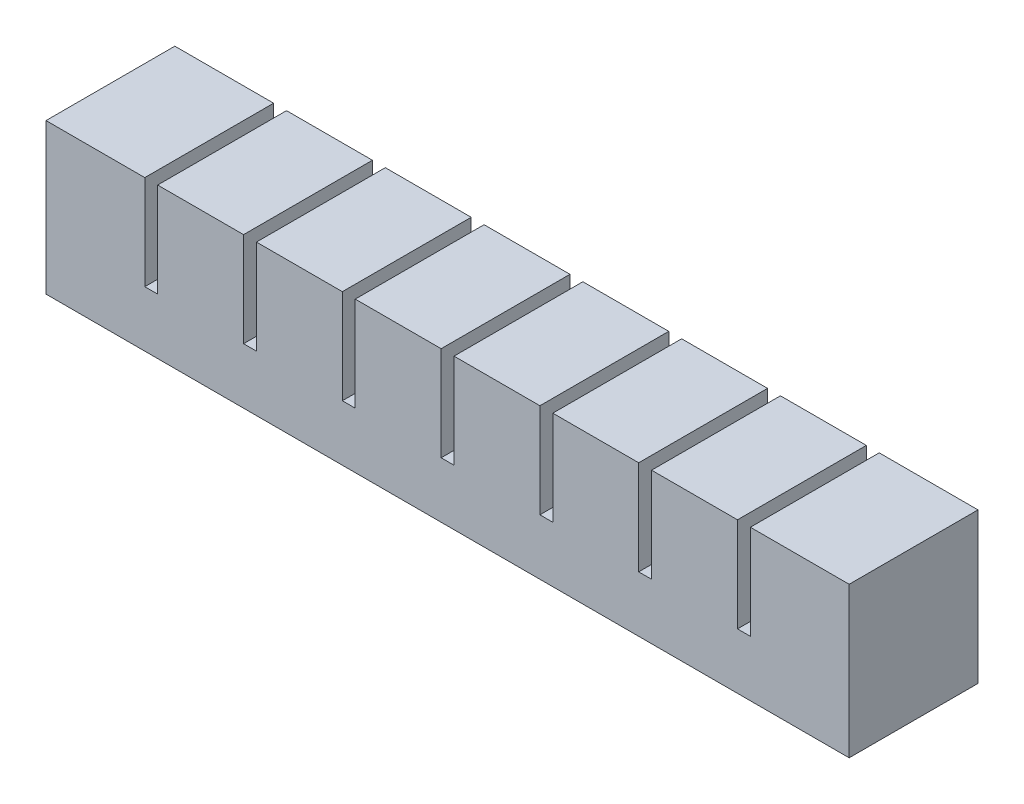
from build123d import *

# Parameters (mm, degrees)
SKETCH1_W           = 20
SKETCH1_H           = 30
BOSS_EXTRUDE1_DEPTH = 30
SKETCH2_W           = 10
SKETCH2_H           = 20
CUT_EXTRUDE1_DEPTH  = 25
SKETCH3_W           = 30
SKETCH3_H           = 8
BOSS_EXTRUDE2_DEPTH = 3
LPATTERN1_COUNT     = 8
LPATTERN1_PITCH     = 23
SKETCH4_W           = 30
SKETCH4_H           = 22
BOSS_EXTRUDE3_DEPTH = 3
SKETCH5_W           = 30
SKETCH5_H           = 30
BOSS_EXTRUDE4_DEPTH = 3
SKETCH6_W           = 151
SKETCH6_H           = 3
CUT_EXTRUDE2_DEPTH  = 3
SKETCH7_W           = 187
SKETCH7_H           = 30
BOSS_EXTRUDE5_DEPTH = 5


with BuildPart() as part:
    # Sketch1 → Boss-Extrude1 (new body)
    with BuildSketch(Plane.XY):
        with Locations((10, 15)):
            Rectangle(SKETCH1_W, SKETCH1_H)
    extrude(amount=BOSS_EXTRUDE1_DEPTH)

    # Sketch2 → Cut-Extrude1 (cut)
    with BuildSketch(Plane.XZ):
        with Locations((10, 15)):
            Rectangle(SKETCH2_W, SKETCH2_H)
    extrude(amount=-CUT_EXTRUDE1_DEPTH, mode=Mode.SUBTRACT)

    # Sketch3 → Boss-Extrude2 (add)
    with BuildSketch(Plane(origin=(20, 0, 0), x_dir=(0, 0, -1), z_dir=(1, 0, 0))):
        with Locations((-15, 4)):
            Rectangle(SKETCH3_W, SKETCH3_H)
    extrude(amount=BOSS_EXTRUDE2_DEPTH)


with BuildPart() as lpattern1_1:
    # LPattern1: pattern copy
    add(part.part.moved(Location(Vector(1, 0, 0) * (1 * LPATTERN1_PITCH))))


with BuildPart() as lpattern1_2:
    # LPattern1: pattern copy
    add(part.part.moved(Location(Vector(1, 0, 0) * (2 * LPATTERN1_PITCH))))


with BuildPart() as lpattern1_3:
    # LPattern1: pattern copy
    add(part.part.moved(Location(Vector(1, 0, 0) * (3 * LPATTERN1_PITCH))))


with BuildPart() as lpattern1_4:
    # LPattern1: pattern copy
    add(part.part.moved(Location(Vector(1, 0, 0) * (4 * LPATTERN1_PITCH))))


with BuildPart() as lpattern1_5:
    # LPattern1: pattern copy
    add(part.part.moved(Location(Vector(1, 0, 0) * (5 * LPATTERN1_PITCH))))


with BuildPart() as lpattern1_6:
    # LPattern1: pattern copy
    add(part.part.moved(Location(Vector(1, 0, 0) * (6 * LPATTERN1_PITCH))))


with BuildPart() as lpattern1_7:
    # LPattern1: pattern copy
    add(part.part.moved(Location(Vector(1, 0, 0) * (7 * LPATTERN1_PITCH))))

    # Combine1: union part, LPattern1_1, LPattern1_2, LPattern1_3, LPattern1_4, LPattern1_5, LPattern1_6
    add(part.part)
    add(lpattern1_1.part)
    add(lpattern1_2.part)
    add(lpattern1_3.part)
    add(lpattern1_4.part)
    add(lpattern1_5.part)
    add(lpattern1_6.part)

    # Sketch4 → Boss-Extrude3 (add)
    with BuildSketch(Plane(origin=(181, 0, 0), x_dir=(0, 0, -1), z_dir=(1, 0, 0))):
        with Locations((-15, 19)):
            Rectangle(SKETCH4_W, SKETCH4_H)
    extrude(amount=BOSS_EXTRUDE3_DEPTH)

    # Sketch5 → Boss-Extrude4 (add)
    with BuildSketch(Plane.ZY):
        with Locations((15, 15)):
            Rectangle(SKETCH5_W, SKETCH5_H)
    extrude(amount=BOSS_EXTRUDE4_DEPTH)

    # Sketch6 → Cut-Extrude2 (cut)
    with BuildSketch(Plane.XZ):
        with Locations((90.5, 15)):
            Rectangle(SKETCH6_W, SKETCH6_H)
    extrude(amount=-CUT_EXTRUDE2_DEPTH, mode=Mode.SUBTRACT)

    # Sketch7 → Boss-Extrude5 (add)
    with BuildSketch(Plane.XZ):
        with Locations((90.5, 15)):
            Rectangle(SKETCH7_W, SKETCH7_H)
    extrude(amount=BOSS_EXTRUDE5_DEPTH)


solid = lpattern1_7.part
